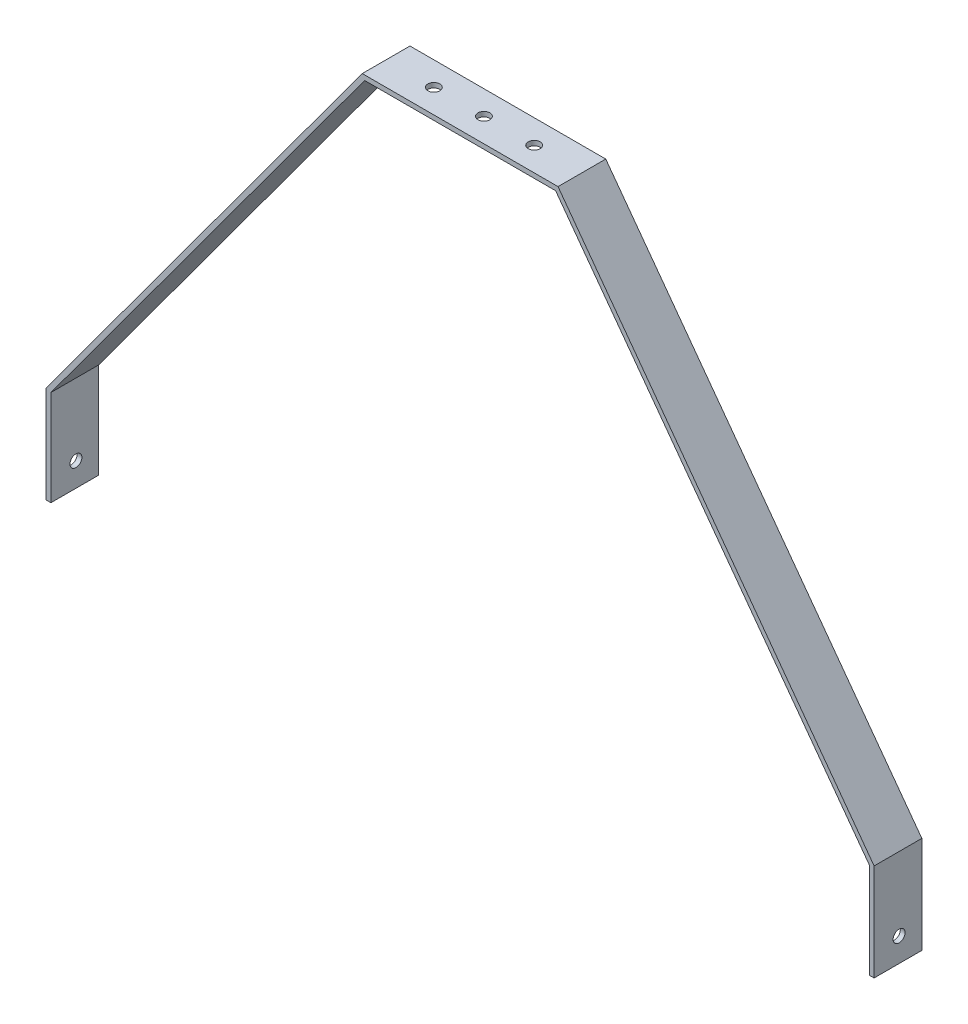
from build123d import *

# Parameters (mm, degrees)
BOSS_EXTRUDE1_DEPTH     = 20
CUT_EXTRUDE1_DEPTH      = 90
CUT_EXTRUDE1_DEPTH_BACK = 479
SKETCH10_R              = 2.5
CUT_EXTRUDE2_DEPTH      = 47
CUT_EXTRUDE2_DEPTH_BACK = 47
SKETCH11_R              = 2.5


with BuildPart() as part:
    # Sketch9 → Boss-Extrude1 (new body)
    with BuildSketch(Plane.XY):
        Polygon((-158.103055268, -153.493142729), (-158.103055268, -113.493142729), (-26.676129575, 65.42293593), (53.323870425, 65.42293593), (184.750796118, -113.493142729), (184.750796118, -153.493142729), (186.750796118, -153.493142729), (186.750796118, -112.83750963), (54.33633476, 67.42293593), (-27.68859391, 67.42293593), (-160.103055268, -112.83750963), (-160.103055268, -153.493142729), align=None)
    extrude(amount=BOSS_EXTRUDE1_DEPTH)

    # Sketch10 → Cut-Extrude1 (cut, two sides: drawn at the far end of the back side and taken through both)
    with BuildSketch(Plane(origin=(186.750796118, 0, 0), x_dir=(0, 0, -1), z_dir=(1, 0, 0)).offset(-CUT_EXTRUDE1_DEPTH_BACK)):
        with Locations((-9.534610309, -143.493142729)):
            Circle(SKETCH10_R)
    extrude(amount=CUT_EXTRUDE1_DEPTH + CUT_EXTRUDE1_DEPTH_BACK, mode=Mode.SUBTRACT)

    # Sketch11 → Cut-Extrude2 (cut, two sides: drawn at the far end of the back side and taken through both)
    with BuildSketch(Plane(origin=(0, 67.42293593, 0), x_dir=(1, 0, 0), z_dir=(0, 1, 0)).offset(-CUT_EXTRUDE2_DEPTH_BACK)):
        with Locations((-7.68859391, -10)):
            Circle(SKETCH11_R)
        with Locations((34.33633476, -10)):
            Circle(SKETCH11_R)
        with Locations((13.31140609, -9.999992232)):
            Circle(SKETCH11_R)
    extrude(amount=CUT_EXTRUDE2_DEPTH + CUT_EXTRUDE2_DEPTH_BACK, mode=Mode.SUBTRACT)


solid = part.part
